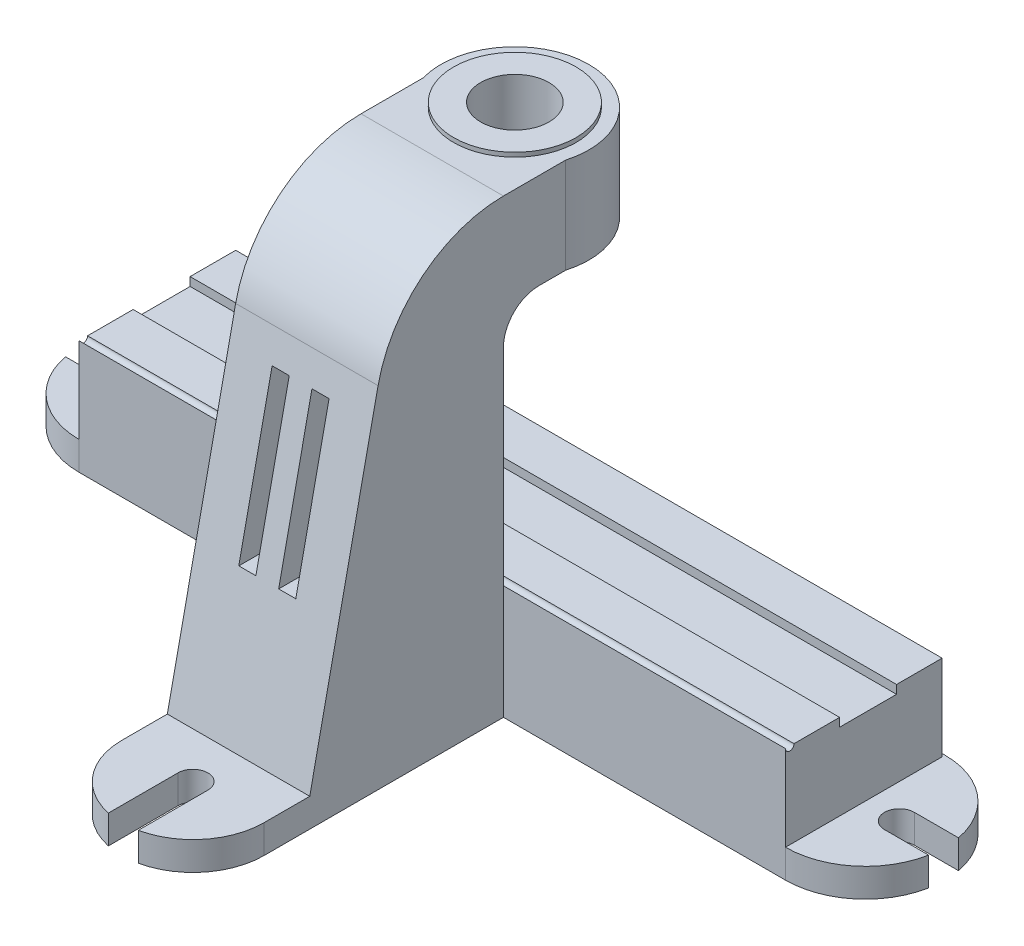
from build123d import *

# Parameters (mm, degrees)
BOSS_EXTRUDE1_DEPTH = 50
SKETCH2_R           = 52
BOSS_EXTRUDE2_DEPTH = 67
SKETCH3_R           = 43
BOSS_EXTRUDE3_DEPTH = 3
CUT_EXTRUDE1_REACH  = 322
SKETCH4_R           = 24
SKETCH5_R           = 33
CUT_EXTRUDE2_DEPTH  = 4
BOSS_EXTRUDE4_DEPTH = 248
SKETCH7_R           = 3
CUT_EXTRUDE3_DEPTH  = 248
BOSS_EXTRUDE5_DEPTH = 20
SKETCH9_R           = 50
BOSS_EXTRUDE6_DEPTH = 20
CUT_EXTRUDE4_REACH  = 22
FILLET1_R           = 25
CUT_EXTRUDE5_DEPTH  = 34
SKETCH12_W          = 78
SKETCH12_H          = 64
CUT_EXTRUDE6_DEPTH  = 240
SKETCH13_W          = 12
SKETCH13_H          = 110
CUT_EXTRUDE7_DEPTH  = 240


with BuildPart() as part:
    # Sketch1 → Boss-Extrude1 (new body, symmetric)
    with BuildSketch(Plane(origin=(0, 0, 0), x_dir=(0, 0, -1), z_dir=(1, 0, 0))):
        with BuildLine():
            Line((-226, 0), (54, 0))
            Line((54, 0), (54, 20))
            Line((54, 20), (52, 20))
            Line((52, 20), (52, 80))
            Line((52, 80), (20, 80))
            Line((20, 80), (20, 74))
            Line((20, 74), (-20, 74))
            Line((-20, 74), (-20, 80))
            Line((-20, 80), (-58, 80))
            Line((-58, 80), (-58, 250))
            Line((-58, 250), (0, 250))
            Line((0, 250), (0, 317))
            Line((0, 317), (-58, 317))
            ThreePointArc((-58, 317), (-114.640297133, 296.941952651), (-146.034066228, 245.708372014))
            Line((-146.034066228, 245.708372014), (-194, 20))
            Line((-194, 20), (-226, 20))
            Line((-226, 20), (-226, 0))
        make_face()
    extrude(amount=BOSS_EXTRUDE1_DEPTH, both=True)

    # Sketch2 → Boss-Extrude2 (add)
    with BuildSketch(Plane(origin=(0, 317, 0), x_dir=(1, 0, 0), z_dir=(0, 1, 0))):
        Circle(SKETCH2_R)
    extrude(amount=-BOSS_EXTRUDE2_DEPTH)

    # Sketch3 → Boss-Extrude3 (add)
    with BuildSketch(Plane(origin=(0, 317, 0), x_dir=(1, 0, 0), z_dir=(0, 1, 0))):
        Circle(SKETCH3_R)
    extrude(amount=BOSS_EXTRUDE3_DEPTH)

    # Sketch4 → Cut-Extrude1 (cut, up to next)
    with BuildSketch(Plane(origin=(0, 320, 0), x_dir=(1, 0, 0), z_dir=(0, 1, 0)), mode=Mode.PRIVATE) as cut_extrude1_sk1:
        Circle(SKETCH4_R)
    cut_extrude1_tool1 = extrude(cut_extrude1_sk1.sketch, amount=-CUT_EXTRUDE1_REACH, mode=Mode.PRIVATE) & part.part
    add(cut_extrude1_tool1.solids().sort_by_distance((0, 320, 0))[0], mode=Mode.SUBTRACT)

    # Sketch5 → Cut-Extrude2 (cut)
    with BuildSketch(Plane.XZ.offset(-250)):
        Circle(SKETCH5_R)
    extrude(amount=-CUT_EXTRUDE2_DEPTH, mode=Mode.SUBTRACT)

    # Sketch6 → Boss-Extrude4 (add, symmetric)
    with BuildSketch(Plane(origin=(0, 0, 0), x_dir=(0, 0, -1), z_dir=(1, 0, 0))):
        Polygon((-58, 80), (-58, 0), (54, 0), (54, 20), (52, 20), (52, 80), (20, 80), (20, 74), (-20, 74), (-20, 80), align=None)
    extrude(amount=BOSS_EXTRUDE4_DEPTH, both=True)

    # Sketch7 → Cut-Extrude3 (cut, symmetric)
    with BuildSketch(Plane(origin=(0, 0, 0), x_dir=(0, 0, -1), z_dir=(1, 0, 0))):
        with Locations((-55, 80)):
            Circle(SKETCH7_R)
    extrude(amount=CUT_EXTRUDE3_DEPTH, both=True, mode=Mode.SUBTRACT)

    # Sketch8 → Boss-Extrude5 (add)
    with BuildSketch(Plane.XZ):
        with BuildLine():
            Line((-272, 12.5), (-303.006817759, 12.5))
            ThreePointArc((-303.006817759, 12.5), (-192, 2), (-303.006817759, -8.5))
            Line((-303.006817759, -8.5), (-272, -8.5))
            ThreePointArc((-272, -8.5), (-261.5, 2), (-272, 12.5))
        make_face()
        with BuildLine():
            Line((272, -8.5), (303.006817759, -8.5))
            ThreePointArc((303.006817759, -8.5), (192, 2), (303.006817759, 12.5))
            Line((303.006817759, 12.5), (272, 12.5))
            ThreePointArc((272, 12.5), (261.5, 2), (272, -8.5))
        make_face()
    extrude(amount=-BOSS_EXTRUDE5_DEPTH)

    # Sketch9 → Boss-Extrude6 (add)
    with BuildSketch(Plane(origin=(0, 20, 0), x_dir=(1, 0, 0), z_dir=(0, 1, 0))):
        with Locations((0, -226)):
            Circle(SKETCH9_R)
    extrude(amount=-BOSS_EXTRUDE6_DEPTH)

    # Sketch10 → Cut-Extrude4 (cut, up to next)
    with BuildSketch(Plane(origin=(0, 20, 0), x_dir=(1, 0, 0), z_dir=(0, 1, 0)), mode=Mode.PRIVATE) as cut_extrude4_sk1:
        with BuildLine():
            ThreePointArc((10.5, -226), (0, -215.5), (-10.5, -226))
            Line((-10.5, -226), (-10.5, -291))
            ThreePointArc((-10.5, -291), (0, -301.5), (10.5, -291))
            Line((10.5, -291), (10.5, -226))
        make_face()
    cut_extrude4_tool1 = extrude(cut_extrude4_sk1.sketch, amount=-CUT_EXTRUDE4_REACH, mode=Mode.PRIVATE) & part.part
    add(cut_extrude4_tool1.solids().sort_by_distance((0, 20, 258.5))[0], mode=Mode.SUBTRACT)

    # Fillet1
    fillet1_edges = [part.edges().sort_by_distance(p)[0] for p in [
        (0, 250, 58),
    ]]
    fillet(fillet1_edges, radius=FILLET1_R)

    # Sketch11 → Cut-Extrude5 (cut, symmetric)
    with BuildSketch(Plane(origin=(0, 0, 0), x_dir=(0, 0, -1), z_dir=(1, 0, 0))):
        with BuildLine():
            Line((-130.383565565, 242.382439212), (-181.892953201, 0))
            Line((-181.892953201, 0), (0, 0))
            Line((0, 0), (0, 64))
            Line((0, 64), (-74, 64))
            Line((-74, 64), (-74, 225))
            ThreePointArc((-74, 225), (-61.991378029, 253.991378029), (-33, 266))
            Line((-33, 266), (-33, 301))
            Line((-33, 301), (-58, 301))
            ThreePointArc((-58, 301), (-104.570910976, 284.507827735), (-130.383565565, 242.382439212))
        make_face()
    extrude(amount=CUT_EXTRUDE5_DEPTH, both=True, mode=Mode.SUBTRACT)

    # Sketch12 → Cut-Extrude6 (cut, symmetric)
    with BuildSketch(Plane(origin=(0, 0, 0), x_dir=(0, 0, -1), z_dir=(1, 0, 0))):
        with Locations((-3, 32)):
            Rectangle(SKETCH12_W, SKETCH12_H)
    extrude(amount=CUT_EXTRUDE6_DEPTH, both=True, mode=Mode.SUBTRACT)

    # Sketch13 → Cut-Extrude7 (cut, symmetric)
    with BuildSketch(Plane(origin=(0, 0, 58), x_dir=(-1, 0, 0), z_dir=(0, 0, -1))):
        with Locations((14, 170)):
            Rectangle(SKETCH13_W, SKETCH13_H)
        with Locations((-14, 170)):
            Rectangle(SKETCH13_W, SKETCH13_H)
    extrude(amount=CUT_EXTRUDE7_DEPTH, both=True, mode=Mode.SUBTRACT)


solid = part.part
